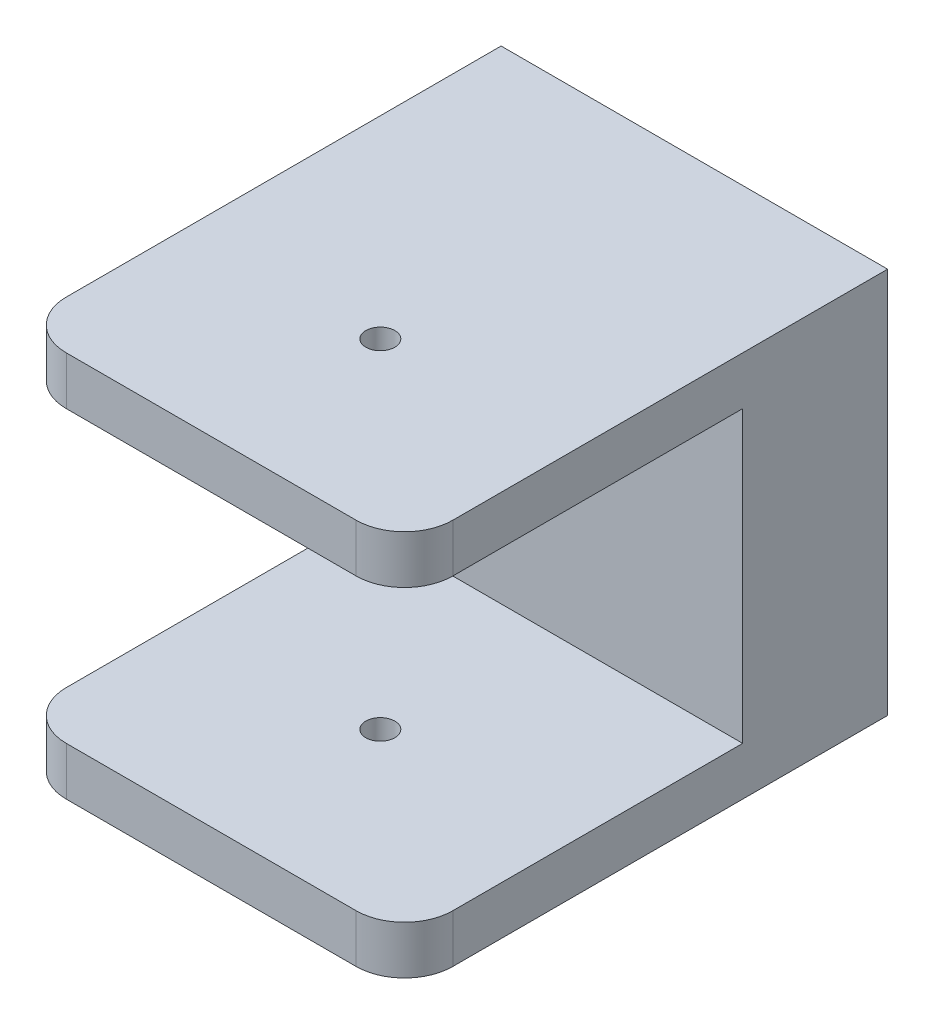
from build123d import *

# Parameters (mm, degrees)
SKETCH1_W               = 80
SKETCH1_H               = 80
SKETCH1_R               = 3
BOSS_EXTRUDE1_DEPTH     = 100
SKETCH2_W               = 80
SKETCH2_H               = 60
CUT_EXTRUDE1_DEPTH      = 70
SKETCH3_R               = 3
CUT_EXTRUDE2_DEPTH      = 1
CUT_EXTRUDE2_DEPTH_BACK = 81
FILLET1_R               = 10


with BuildPart() as part:
    # Sketch1 → Boss-Extrude1 (new body)
    with BuildSketch(Plane.XY):
        with Locations((40, 40)):
            Rectangle(SKETCH1_W, SKETCH1_H)
        with Locations((40, 40)):
            Circle(SKETCH1_R, mode=Mode.SUBTRACT)
    extrude(amount=BOSS_EXTRUDE1_DEPTH)

    # Sketch2 → Cut-Extrude1 (cut)
    with BuildSketch(Plane.XY.offset(100)):
        with Locations((40, 40)):
            Rectangle(SKETCH2_W, SKETCH2_H)
    extrude(amount=-CUT_EXTRUDE1_DEPTH, mode=Mode.SUBTRACT)

    # Sketch3 → Cut-Extrude2 (cut, two sides)
    with BuildSketch(Plane(origin=(0, 80, 0), x_dir=(1, 0, 0), z_dir=(0, 1, 0))) as cut_extrude2_sk:
        with Locations((40, -65)):
            Circle(SKETCH3_R)
    extrude(amount=CUT_EXTRUDE2_DEPTH, mode=Mode.SUBTRACT)
    extrude(cut_extrude2_sk.sketch, amount=-CUT_EXTRUDE2_DEPTH_BACK, mode=Mode.SUBTRACT)

    # Fillet1
    fillet1_edges = [part.edges().sort_by_distance(p)[0] for p in [
        (80, 5, 100),
        (80, 75, 100),
        (0, 5, 100),
        (0, 75, 100),
    ]]
    fillet(fillet1_edges, radius=FILLET1_R)


solid = part.part
